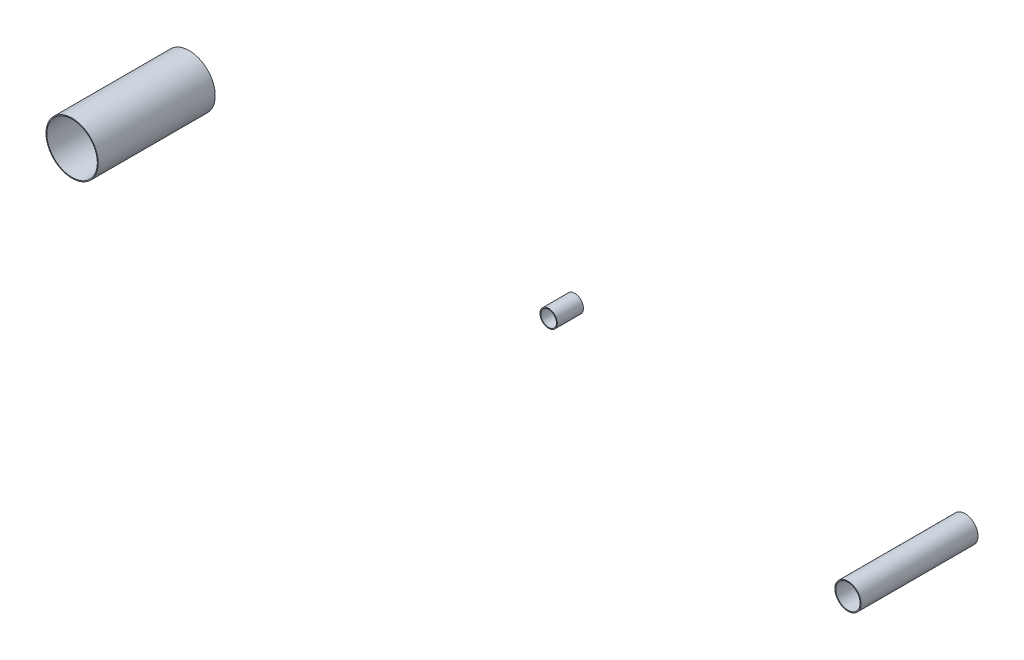
from build123d import *

# Parameters (mm, degrees)
SWEEP_THIN2_PROFILE_R   = 30
SWEEP_THIN2_PROFILE_R_2 = 29
SWEEP_THIN3_PROFILE_R   = 10
SWEEP_THIN3_PROFILE_R_2 = 9
SWEEP_THIN4_PROFILE_R   = 15
SWEEP_THIN4_PROFILE_R_2 = 14


with BuildPart() as part:
    # Sweep-Thin2: sweep along a curve in space
    with BuildLine() as sweep_thin2_path:
        Line((-31937.449283249, -16257.859506292, 41013.290696056), (-31937.449283249, -16257.859506292, 40878.786131159))
    # Sweep-Thin2 profile (on start of the path) → Sweep-Thin2 (sweep)
    with BuildSketch(Plane(origin=(-31937.449283249, -16257.859506292, 41013.290696056), x_dir=(0, -1, 0), z_dir=(0, 0, -1))):
        Circle(SWEEP_THIN2_PROFILE_R)
        Circle(SWEEP_THIN2_PROFILE_R_2, mode=Mode.SUBTRACT)
    sweep(path=sweep_thin2_path.line)


with BuildPart() as body_2:
    # Sweep-Thin3: sweep along a curve in space
    with BuildLine() as sweep_thin3_path:
        Line((-31494.426581806, -16257.859506292, 40878.786131159), (-31494.426581806, -16257.859506292, 40908.786131159))
    # Sweep-Thin3 profile (on start of the path) → Sweep-Thin3 (sweep)
    with BuildSketch(Plane(origin=(-31494.426581806, -16257.859506292, 40878.786131159), x_dir=(1, 0, 0), z_dir=(0, 0, 1))):
        Circle(SWEEP_THIN3_PROFILE_R)
        Circle(SWEEP_THIN3_PROFILE_R_2, mode=Mode.SUBTRACT)
    sweep(path=sweep_thin3_path.line)


with BuildPart() as body_3:
    # Sweep-Thin4: sweep along a curve in space
    with BuildLine() as sweep_thin4_path:
        Line((-31046.033515707, -16257.859506292, 41013.290696056), (-31046.033515707, -16257.859506292, 40878.786131159))
    # Sweep-Thin4 profile (on start of the path) → Sweep-Thin4 (sweep)
    with BuildSketch(Plane(origin=(-31046.033515707, -16257.859506292, 41013.290696056), x_dir=(-1, 0, 0), z_dir=(0, 0, -1))):
        Circle(SWEEP_THIN4_PROFILE_R)
        Circle(SWEEP_THIN4_PROFILE_R_2, mode=Mode.SUBTRACT)
    sweep(path=sweep_thin4_path.line)


solid = Compound([part.part, body_2.part, body_3.part])
